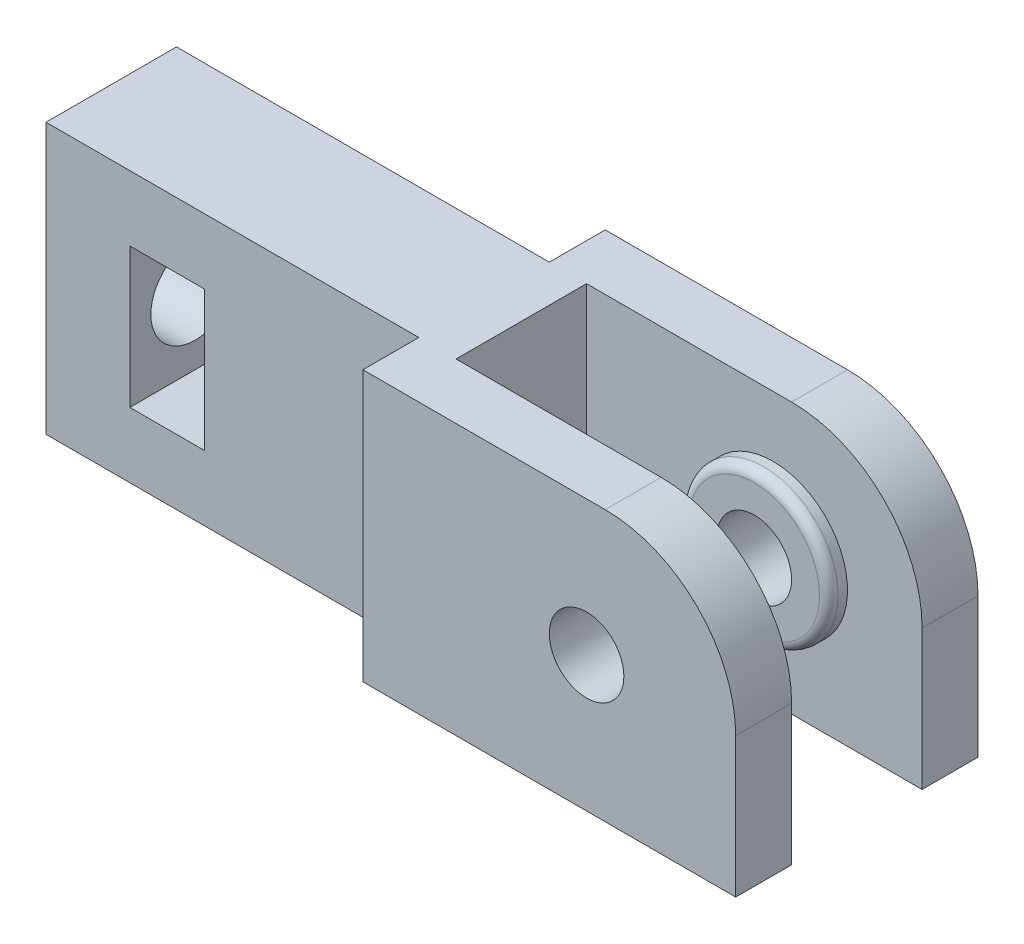
from build123d import *

# Parameters (mm, degrees)
BOSS_EXTRU_1_DEPTH      = 14.5
CONG_5_R                = 7
ESQUISSE3_R             = 4
BOSS_EXTRU_2_DEPTH      = 1
CONG_2_R                = 0.5
ESQUISSE4_R             = 2
ENL_V_MAT_EXTRU_1_DEPTH = 5
ESQUISSE5_R             = 2.375
ENL_V_MAT_EXTRU_2_DEPTH = 41
ESQUISSE6_W             = 4
ESQUISSE6_H             = 7.5
ENL_V_MAT_EXTRU_3_DEPTH = 11


with BuildPart() as part:
    # Esquisse2 → Boss.-Extru.1 (new body)
    with BuildSketch(Plane(origin=(0, 0, 0), x_dir=(1, 0, 0), z_dir=(0, 1, 0))):
        Polygon((0, 0), (0, 3.5), (20, 3.5), (20, 6.5), (40, 6.5), (40, 3.5), (22, 3.5), (22, 0), align=None)
    extrude(amount=BOSS_EXTRU_1_DEPTH)

    # Congé5
    cong_5_edges = [part.edges().sort_by_distance(p)[0] for p in [
        (40, 14.5, -5),
    ]]
    fillet(cong_5_edges, radius=CONG_5_R)

    # Esquisse3 → Boss.-Extru.2 (add)
    with BuildSketch(Plane.XY.offset(-3.5)):
        with Locations((32, 7.25)):
            Circle(ESQUISSE3_R)
    extrude(amount=BOSS_EXTRU_2_DEPTH)

    # Congé2
    cong_2_edges = [part.edges().sort_by_distance(p)[0] for p in [
        (28, 7.25, -2.5),
    ]]
    fillet(cong_2_edges, radius=CONG_2_R)

    # Esquisse4 → Enlèv. mat.-Extru.1 (cut, through all)
    with BuildSketch(Plane.XY.offset(-2.5)):
        with Locations((32, 7.25)):
            Circle(ESQUISSE4_R)
    extrude(amount=-ENL_V_MAT_EXTRU_1_DEPTH, mode=Mode.SUBTRACT)

    # Symétrie1: part across plane


with BuildPart() as part_1:
    add(part.part)
    add(part.part.mirror(Plane(origin=(22, 14.5, 0), x_dir=(1, 0, 0), z_dir=(0, 0, -1))))

    # Esquisse5 → Enlèv. mat.-Extru.2 (cut, through all)
    with BuildSketch(Plane.ZY):
        with Locations((0, 7.25)):
            Circle(ESQUISSE5_R)
    extrude(amount=-ENL_V_MAT_EXTRU_2_DEPTH, mode=Mode.SUBTRACT)

    # Esquisse6 → Enlèv. mat.-Extru.3 (cut, through all)
    with BuildSketch(Plane(origin=(0, 0, -3.5), x_dir=(-1, 0, 0), z_dir=(0, 0, -1))):
        with Locations((-6.5, 7.25)):
            Rectangle(ESQUISSE6_W, ESQUISSE6_H)
    extrude(amount=-ENL_V_MAT_EXTRU_3_DEPTH, mode=Mode.SUBTRACT)


solid = part_1.part
